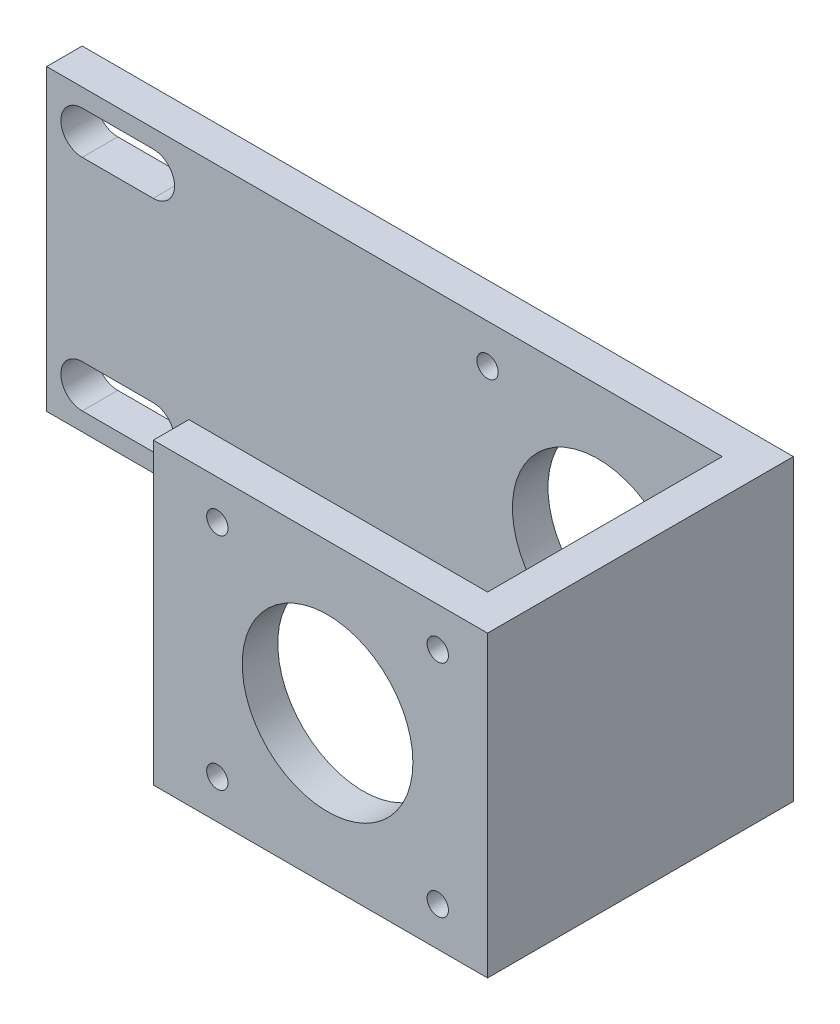
from build123d import *

# Parameters (mm, degrees)
CROQUIS1_W              = 100
CROQUIS1_H              = 42
SALIENTE_EXTRUIR1_DEPTH = 5
CROQUIS2_W              = 5
CROQUIS2_H              = 42
SALIENTE_EXTRUIR2_DEPTH = 38
CROQUIS3_W              = 5
CROQUIS3_H              = 42
SALIENTE_EXTRUIR3_DEPTH = 42
CROQUIS7_R              = 1.5
CORTAR_EXTRUIR1_DEPTH   = 43
CROQUIS8_R              = 12
CORTAR_EXTRUIR2_DEPTH   = 43


with BuildPart() as part:
    # Croquis1 → Saliente-Extruir1 (new body)
    with BuildSketch(Plane.XY):
        Rectangle(CROQUIS1_W, CROQUIS1_H)
        with BuildLine():
            Line((-45, 18.44), (-35.021412409, 18.44))
            ThreePointArc((-35.021412409, 18.44), (-32.021412409, 15.44), (-35.021412409, 12.44))
            Line((-35.021412409, 12.44), (-45, 12.44))
            ThreePointArc((-45, 12.44), (-48, 15.44), (-45, 18.44))
        make_face(mode=Mode.SUBTRACT)
        with BuildLine():
            Line((-45, -12.44), (-35.021412409, -12.44))
            ThreePointArc((-35.021412409, -12.44), (-32.021412409, -15.44), (-35.021412409, -18.44))
            Line((-35.021412409, -18.44), (-45, -18.44))
            ThreePointArc((-45, -18.44), (-48, -15.44), (-45, -12.44))
        make_face(mode=Mode.SUBTRACT)
    extrude(amount=SALIENTE_EXTRUIR1_DEPTH)

    # Croquis2 → Saliente-Extruir2 (add)
    with BuildSketch(Plane.XY.offset(5)):
        with Locations((47.5, 0)):
            Rectangle(CROQUIS2_W, CROQUIS2_H)
    extrude(amount=SALIENTE_EXTRUIR2_DEPTH)

    # Croquis3 → Saliente-Extruir3 (add)
    with BuildSketch(Plane.ZY.offset(-45)):
        with Locations((40.5, 0)):
            Rectangle(CROQUIS3_W, CROQUIS3_H)
    extrude(amount=SALIENTE_EXTRUIR3_DEPTH)

    # Croquis7 → Cortar-Extruir1 (cut)
    with BuildSketch(Plane.XY.offset(43)):
        with BuildLine():
            ThreePointArc((13.5, -15.5), (13.060660172, -14.439339828), (12, -14))
            Line((12, -14), (12, -15.5))
            Line((12, -15.5), (13.5, -15.5))
        make_face()
        with BuildLine():
            Line((12, -15.5), (12, -14))
            ThreePointArc((12, -14), (10.939339828, -16.560660172), (13.5, -15.5))
            Line((13.5, -15.5), (12, -15.5))
        make_face()
        with Locations((12, 15.5)):
            Circle(CROQUIS7_R)
        with Locations((43, 15.5)):
            Circle(CROQUIS7_R)
        with Locations((43, -15.5)):
            Circle(CROQUIS7_R)
    extrude(amount=-CORTAR_EXTRUIR1_DEPTH, mode=Mode.SUBTRACT)

    # Croquis8 → Cortar-Extruir2 (cut)
    with BuildSketch(Plane.XY.offset(43)):
        with Locations((27.5, 0)):
            Circle(CROQUIS8_R)
    extrude(amount=-CORTAR_EXTRUIR2_DEPTH, mode=Mode.SUBTRACT)


solid = part.part
